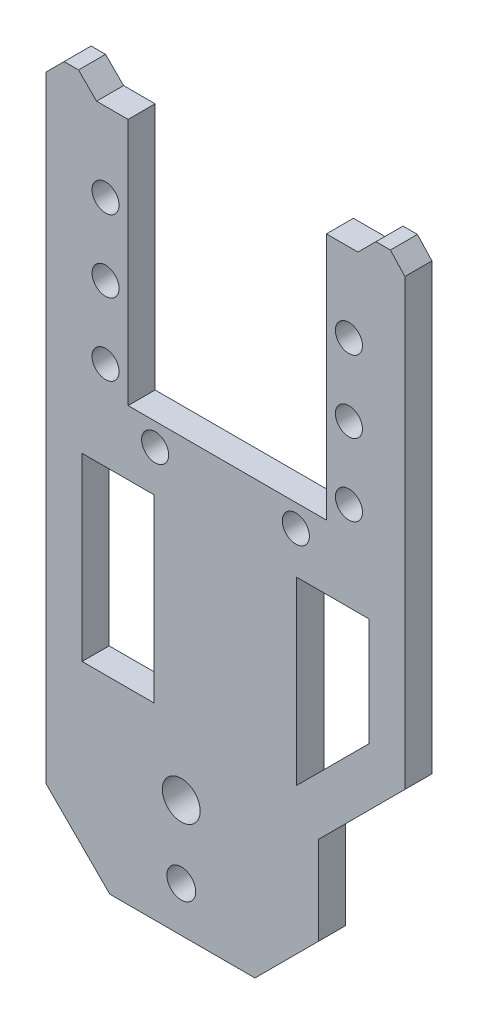
from build123d import *

# Parameters (mm, degrees)
IZIM1_R                     = 2.1
IZIM1_R_2                   = 1.6
Y_KSEKLIK_EKSTR_ZYON1_DEPTH = 3
Y_KSEKLIK_EKSTR_ZYON2_DEPTH = 3
IZIM5_R                     = 1.5
KES_EKSTR_ZYON1_DEPTH       = 4
SKETCH3_W                   = 8
SKETCH3_H                   = 20
CUT_EXTRUDE1_DEPTH          = 10


with BuildPart() as part:
    # Çizim1 → Yükseklik-Ekstrüzyon1 (new body)
    with BuildSketch(Plane.XY.offset(3)):
        with BuildLine():
            Line((-20.1, -15), (-20.1, -83.384802))
            Line((-20.1, -83.384802), (-13.028932188, -90.455869812))
            Line((-13.028932188, -90.455869812), (3.075751729, -90.455869812))
            Line((3.075751729, -90.455869812), (10.146819541, -83.384802))
            Line((10.146819541, -83.384802), (10.146819541, -73.586547015))
            Line((10.146819541, -73.586547015), (19.709913851, -64.023452705))
            Line((19.709913851, -64.023452705), (19.709913851, -14.740055992))
            Line((19.709913851, -14.740055992), (18.1, -13))
            Line((18.1, -13), (16.5, -13))
            Line((16.5, -13), (14.5, -15))
            Line((14.5, -15), (14.5, -41.5))
            ThreePointArc((14.5, -41.5), (14.207106781, -42.207106781), (13.5, -42.5))
            Line((13.5, -42.5), (-13.5, -42.5))
            ThreePointArc((-13.5, -42.5), (-14.207106781, -42.207106781), (-14.5, -41.5))
            Line((-14.5, -41.5), (-14.5, -15))
            Line((-14.5, -15), (-16.5, -13))
            Line((-16.5, -13), (-18.1, -13))
            Line((-18.1, -13), (-20.1, -15))
        make_face()
        with Locations((-5.1, -77.455869812)):
            Circle(IZIM1_R, mode=Mode.SUBTRACT)
        with Locations((-5.1, -85.455869812)):
            Circle(IZIM1_R_2, mode=Mode.SUBTRACT)
    extrude(amount=-Y_KSEKLIK_EKSTR_ZYON1_DEPTH)

    # Çizim4 → Yükseklik-Ekstrüzyon2 (add)
    with BuildSketch(Plane.XY.offset(3)):
        Polygon((-16.5, -13), (-14.5, -15), (-11, -15), (-11, -42.5), (11, -42.5), (11, -15), (14.5, -15), (16.5, -13), (16.5, -43.147363563), (-16.5, -43.147363563), align=None)
    extrude(amount=-Y_KSEKLIK_EKSTR_ZYON2_DEPTH)

    # Çizim5 → Kes-Ekstrüzyon1 (cut)
    with BuildSketch(Plane(origin=(0, 0, 0), x_dir=(-1, 0, 0), z_dir=(0, 0, -1))):
        with Locations((-13.5, -23.75)):
            Circle(IZIM5_R)
        with Locations((-13.5, -31.75)):
            Circle(IZIM5_R)
        with Locations((-13.5, -39.75)):
            Circle(IZIM5_R)
        with Locations((-7.609913851, -45)):
            Circle(IZIM5_R)
        with Locations((8, -45)):
            Circle(IZIM5_R)
        with Locations((13.5, -39.75)):
            Circle(IZIM5_R)
        with Locations((13.5, -31.75)):
            Circle(IZIM5_R)
        with Locations((13.5, -23.75)):
            Circle(IZIM5_R)
    extrude(amount=-KES_EKSTR_ZYON1_DEPTH, mode=Mode.SUBTRACT)

    # Sketch3 → Cut-Extrude1 (cut)
    with BuildSketch(Plane(origin=(0, 0, 0), x_dir=(-1, 0, 0), z_dir=(0, 0, -1))):
        with Locations((12.1, -59.633395866)):
            Rectangle(SKETCH3_W, SKETCH3_H)
        Polygon((-15.709913851, -49.633395866), (-15.709913851, -61.633395866), (-7.709913851, -69.633395866), (-7.709913851, -49.633395866), align=None)
    extrude(amount=-CUT_EXTRUDE1_DEPTH, mode=Mode.SUBTRACT)


solid = part.part
